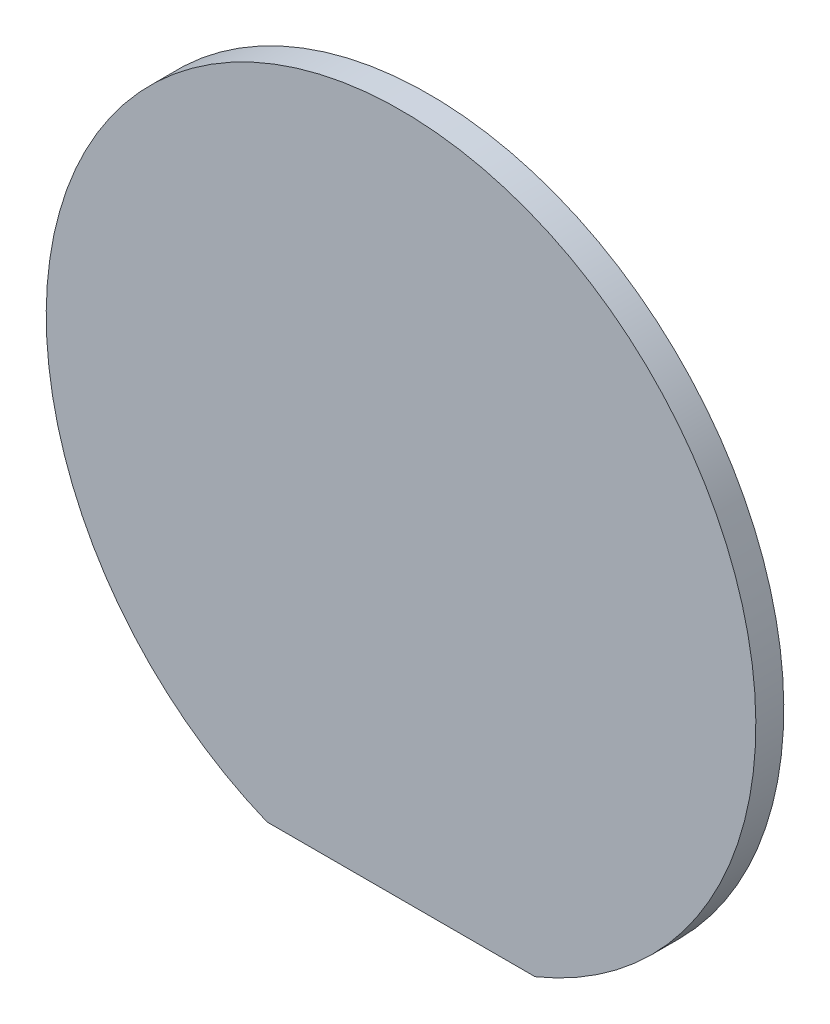
from build123d import *

# Parameters (mm, degrees)
SKETCH_1_R          = 12.7
EXTRUDE_1_DEPTH     = 1
SKETCH_2_W          = 13.590670976
SKETCH_2_H          = 1.925848739
CUT_EXTRUDE_1_DEPTH = 2


with BuildPart() as part:
    # 草图1 → 凸台-拉伸1 (new body)
    with BuildSketch(Plane.XY):
        Circle(SKETCH_1_R)
    extrude(amount=EXTRUDE_1_DEPTH)

    # 草图2 → 切除-拉伸1 (cut, through all)
    with BuildSketch(Plane.XY.offset(1)):
        with Locations((0.907997414, -12.72292437)):
            Rectangle(SKETCH_2_W, SKETCH_2_H)
    extrude(amount=-CUT_EXTRUDE_1_DEPTH, mode=Mode.SUBTRACT)


solid = part.part
